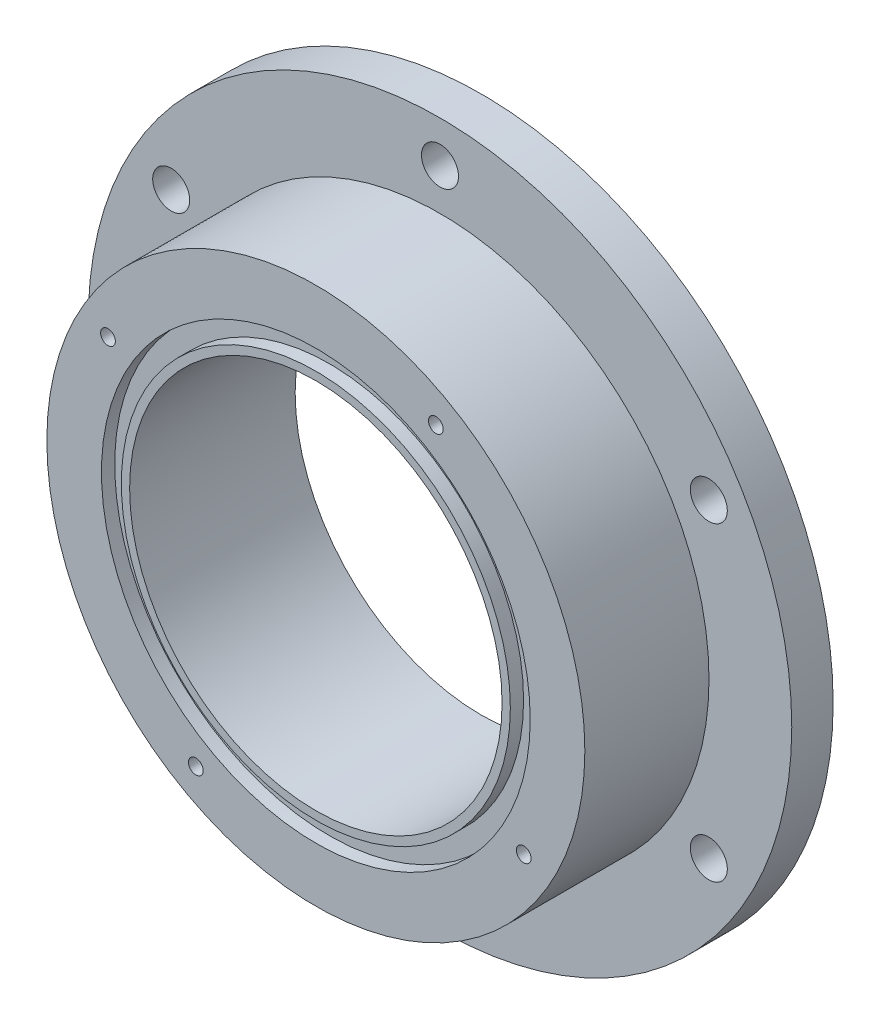
from build123d import *

# Parameters (mm, degrees)
SKETCH1_R           = 53.975
BOSS_EXTRUDE1_DEPTH = 25.4
SKETCH2_OUTSIDE_W   = 140.902
SKETCH2_OUTSIDE_H   = 140.902
SKETCH2_OUTSIDE_R   = 41.275
CUT_EXTRUDE1_DEPTH  = 19.05
SKETCH3_R           = 28.575
CUT_EXTRUDE2_DEPTH  = 26.4
SKETCH6_R           = 32.893
SKETCH6_R_2         = 29.845
CUT_EXTRUDE3_DEPTH  = 2.032
CIRPATTERN2_COUNT   = 4
SKETCH9_R           = 2.840620424
CUT_EXTRUDE4_DEPTH  = 26.4
CIRPATTERN4_COUNT   = 6


with BuildPart() as part:
    # Sketch1 → Boss-Extrude1 (new body)
    with BuildSketch(Plane.XY):
        Circle(SKETCH1_R)
    extrude(amount=BOSS_EXTRUDE1_DEPTH)

    # Sketch2 outside → Cut-Extrude1 (cut)
    with BuildSketch(Plane.XY.offset(25.4)):
        Rectangle(SKETCH2_OUTSIDE_W, SKETCH2_OUTSIDE_H)
        Circle(SKETCH2_OUTSIDE_R, mode=Mode.SUBTRACT)
    extrude(amount=-CUT_EXTRUDE1_DEPTH, mode=Mode.SUBTRACT)

    # Sketch3 → Cut-Extrude2 (cut, through all)
    with BuildSketch(Plane.XY.offset(25.4)):
        Circle(SKETCH3_R)
    extrude(amount=-CUT_EXTRUDE2_DEPTH, mode=Mode.SUBTRACT)

    # Sketch6 → Cut-Extrude3 (cut)
    with BuildSketch(Plane.XY.offset(25.4)):
        Circle(SKETCH6_R)
        Circle(SKETCH6_R_2, mode=Mode.SUBTRACT)
    extrude(amount=-CUT_EXTRUDE3_DEPTH, mode=Mode.SUBTRACT)

    # Sketch8 → #4-40 Tapped Hole1 (revolve, cut)
    with BuildSketch(Plane(origin=(18.415, 31.895715621, 25.4), x_dir=(0, -1, 0), z_dir=(1, 0, 0))):
        Polygon((0, 0), (0, 10.966152758), (1.1303, 10.287), (1.1303, 0), align=None)
    f_4_40_tapped_hole1 = revolve(axis=Axis((18.415, 31.895715621, 31.75), (0, 0, -1)), mode=Mode.SUBTRACT)

    # CirPattern2: #4-40 Tapped Hole1 ×4 about axis
    cirpattern2_axis = Axis((0, 0, 0), (0, 0, 1))
    for i in range(1, CIRPATTERN2_COUNT):
        add(f_4_40_tapped_hole1.rotate(cirpattern2_axis, i * 360 / CIRPATTERN2_COUNT), mode=Mode.SUBTRACT)

    # Sketch9 → Cut-Extrude4 (cut, through all)
    with BuildSketch(Plane(origin=(0, 0, 0), x_dir=(-1, 0, 0), z_dir=(0, 0, -1))):
        with Locations((0, 47.625)):
            Circle(SKETCH9_R)
    cut_extrude4 = extrude(amount=-CUT_EXTRUDE4_DEPTH, mode=Mode.SUBTRACT)

    # CirPattern4: Cut-Extrude4 ×6 about axis
    cirpattern4_axis = Axis((0, 0, 0), (0, 0, 1))
    for i in range(1, CIRPATTERN4_COUNT):
        add(cut_extrude4.rotate(cirpattern4_axis, i * 360 / CIRPATTERN4_COUNT), mode=Mode.SUBTRACT)


solid = part.part
